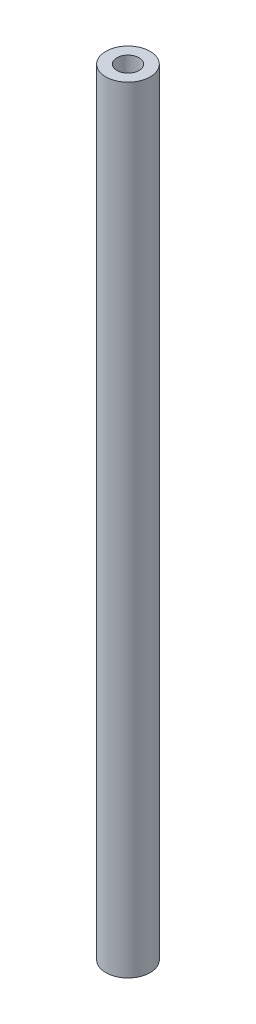
from build123d import *

# Parameters (mm, degrees)
SKETCH2_R             = 5
BOSS_EXTRUDE2_DEPTH   = 175
M6_TAPPED_HOLE1_D     = 5
M6_TAPPED_HOLE1_DEPTH = 16
M6_TAPPED_HOLE1_TIP   = 1.502151548
M6_TAPPED_HOLE2_D     = 5
M6_TAPPED_HOLE2_DEPTH = 16
M6_TAPPED_HOLE2_TIP   = 1.502151548


with BuildPart() as part:
    # Sketch2 → Boss-Extrude2 (new body)
    with BuildSketch(Plane(origin=(0, 0, 0), x_dir=(1, 0, 0), z_dir=(0, 1, 0))):
        Circle(SKETCH2_R)
    extrude(amount=BOSS_EXTRUDE2_DEPTH)

    # M6 Tapped Hole1
    with Locations(Plane(origin=(0, 175, 0), x_dir=(1, 0, 0), z_dir=(0, 1, 0))):
        with Locations((0, 0)):
            Hole(M6_TAPPED_HOLE1_D / 2, depth=M6_TAPPED_HOLE1_DEPTH)
            with Locations((0, 0, -(M6_TAPPED_HOLE1_DEPTH + M6_TAPPED_HOLE1_TIP / 2))):  # 118° drill point
                Cone(0, M6_TAPPED_HOLE1_D / 2, M6_TAPPED_HOLE1_TIP, mode=Mode.SUBTRACT)

    # M6 Tapped Hole2
    with Locations(Plane(origin=(0, 0, 0), x_dir=(-1, 0, 0), z_dir=(0, -1, 0))):
        with Locations((0, 0)):
            Hole(M6_TAPPED_HOLE2_D / 2, depth=M6_TAPPED_HOLE2_DEPTH)
            with Locations((0, 0, -(M6_TAPPED_HOLE2_DEPTH + M6_TAPPED_HOLE2_TIP / 2))):  # 118° drill point
                Cone(0, M6_TAPPED_HOLE2_D / 2, M6_TAPPED_HOLE2_TIP, mode=Mode.SUBTRACT)


solid = part.part
